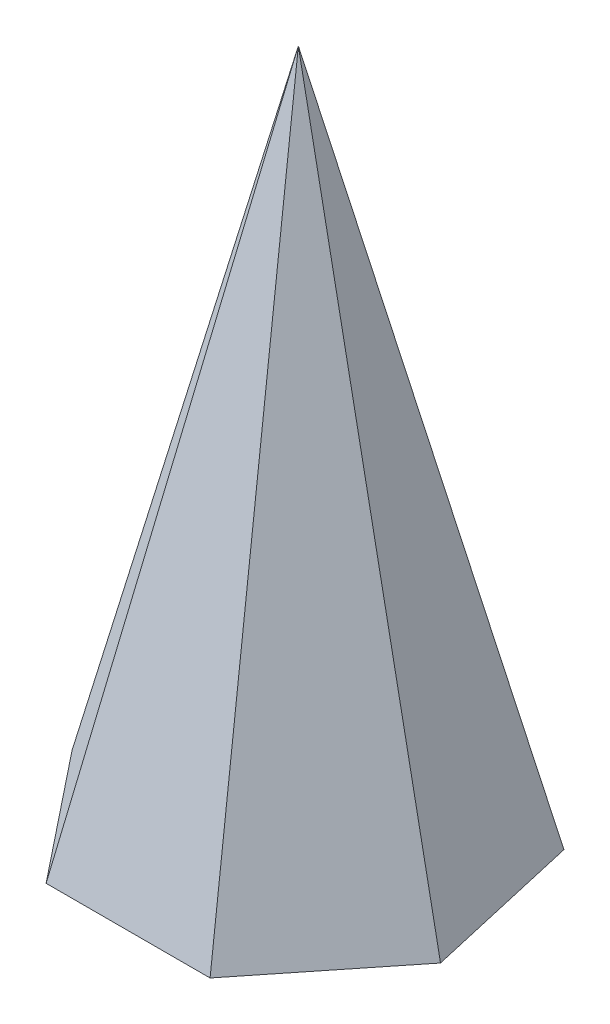
from build123d import *


with BuildPart() as part:
    # Sketch1 → Loft1 section 0
    with BuildSketch(Plane(origin=(0, 0, 0), x_dir=(1, 0, 0), z_dir=(0, 1, 0)), mode=Mode.PRIVATE) as loft1_s0:
        Polygon((5.410441731, -1.234898019), (4.338837391, 3.460107358), (0, 5.549581321), (-4.338837391, 3.460107358), (-5.410441731, -1.234898019), (-2.407873094, -5), (2.407873094, -5), align=None)
    loft([Vertex(0, 20, 0), loft1_s0.sketch])


solid = part.part
